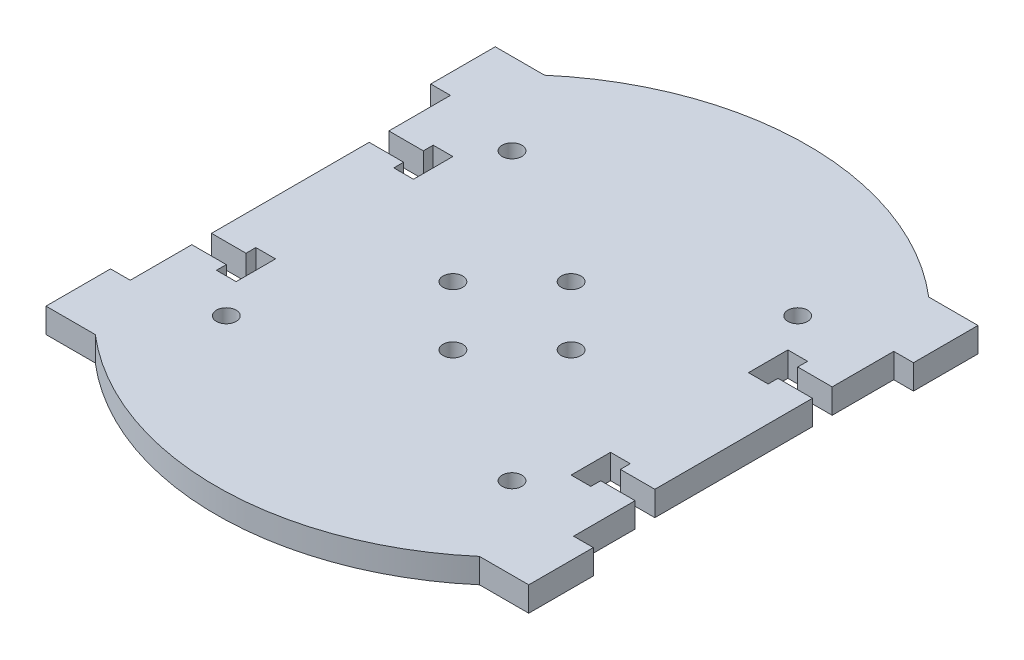
from build123d import *

# Parameters (mm, degrees)
SKETCH1_R           = 2
BOSS_EXTRUDE1_DEPTH = 5


with BuildPart() as part:
    # Sketch1 → Boss-Extrude1 (new body)
    with BuildSketch(Plane(origin=(0, 0, 0), x_dir=(1, 0, 0), z_dir=(0, 1, 0))):
        with BuildLine():
            Line((-49, 45.6), (-49, 32.5))
            Line((-49, 32.5), (-45, 32.5))
            Line((-45, 32.5), (-45, 20))
            Line((-45, 20), (-38, 20))
            Line((-38, 20), (-38, 22))
            Line((-38, 22), (-34, 22))
            Line((-34, 22), (-34, 14))
            Line((-34, 14), (-38, 14))
            Line((-38, 14), (-38, 16))
            Line((-38, 16), (-45, 16))
            Line((-45, 16), (-45, -16))
            Line((-45, -16), (-38, -16))
            Line((-38, -16), (-38, -14))
            Line((-38, -14), (-34, -14))
            Line((-34, -14), (-34, -22))
            Line((-34, -22), (-38, -22))
            Line((-38, -22), (-38, -20))
            Line((-38, -20), (-45, -20))
            Line((-45, -20), (-45, -32.5))
            Line((-45, -32.5), (-49, -32.5))
            Line((-49, -32.5), (-49, -45.6))
            Line((-49, -45.6), (-39, -45.6))
            ThreePointArc((-39, -45.6), (0, -60.002999925), (39, -45.6))
            Line((39, -45.6), (49, -45.6))
            Line((49, -45.6), (49, -32.5))
            Line((49, -32.5), (45, -32.5))
            Line((45, -32.5), (45, -20))
            Line((45, -20), (38, -20))
            Line((38, -20), (38, -22))
            Line((38, -22), (34, -22))
            Line((34, -22), (34, -14))
            Line((34, -14), (38, -14))
            Line((38, -14), (38, -16))
            Line((38, -16), (45, -16))
            Line((45, -16), (45, 16))
            Line((45, 16), (38, 16))
            Line((38, 16), (38, 14))
            Line((38, 14), (34, 14))
            Line((34, 14), (34, 22))
            Line((34, 22), (38, 22))
            Line((38, 22), (38, 20))
            Line((38, 20), (45, 20))
            Line((45, 20), (45, 32.5))
            Line((45, 32.5), (49, 32.5))
            Line((49, 32.5), (49, 45.6))
            Line((49, 45.6), (38.995384342, 45.6))
            ThreePointArc((38.995384342, 45.6), (0, 60), (-38.995384342, 45.6))
            Line((-38.995384342, 45.6), (-49, 45.6))
        make_face()
        with Locations((-12, 0)):
            Circle(SKETCH1_R, mode=Mode.SUBTRACT)
        with Locations((0, 12)):
            Circle(SKETCH1_R, mode=Mode.SUBTRACT)
        with Locations((12, 0)):
            Circle(SKETCH1_R, mode=Mode.SUBTRACT)
        with Locations((0, -12)):
            Circle(SKETCH1_R, mode=Mode.SUBTRACT)
        with Locations((29, 29)):
            Circle(SKETCH1_R, mode=Mode.SUBTRACT)
        with Locations((29, -29)):
            Circle(SKETCH1_R, mode=Mode.SUBTRACT)
        with Locations((-29, -29)):
            Circle(SKETCH1_R, mode=Mode.SUBTRACT)
        with Locations((-29, 29)):
            Circle(SKETCH1_R, mode=Mode.SUBTRACT)
    extrude(amount=BOSS_EXTRUDE1_DEPTH)


solid = part.part
